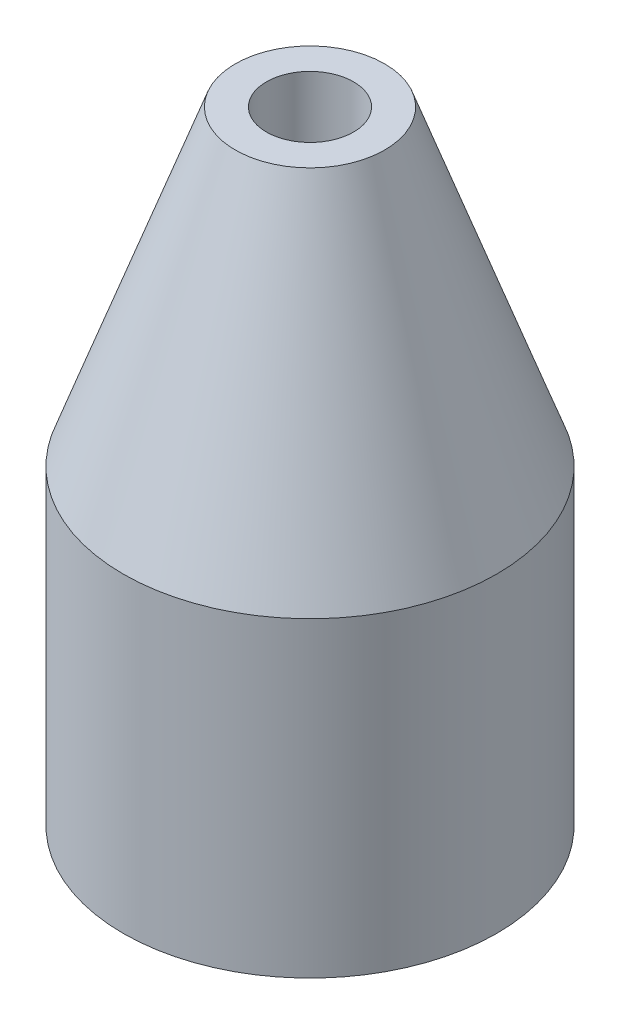
from build123d import *

# Parameters (mm, degrees)
SKETCH1_W          = 3.81
SKETCH1_H          = 6.35
SKETCH2_R          = 0.889
CUT_EXTRUDE1_DEPTH = 13.7


with BuildPart() as part:
    # Sketch1 → Revolve1 (revolve)
    with BuildSketch(Plane.XY):
        Polygon((3.81, 12.7), (3.81, 6.35), (7.62, 6.35), (5.334, 12.7), align=None)
        with Locations((5.715, 3.175)):
            Rectangle(SKETCH1_W, SKETCH1_H)
    revolve(axis=Axis((3.81, 0, 0), (0, 1, 0)))

    # Sketch2 → Cut-Extrude1 (cut, through all)
    with BuildSketch(Plane(origin=(0, 12.7, 0), x_dir=(1, 0, 0), z_dir=(0, 1, 0))):
        with Locations((3.81, 0)):
            Circle(SKETCH2_R)
    extrude(amount=-CUT_EXTRUDE1_DEPTH, mode=Mode.SUBTRACT)


solid = part.part
